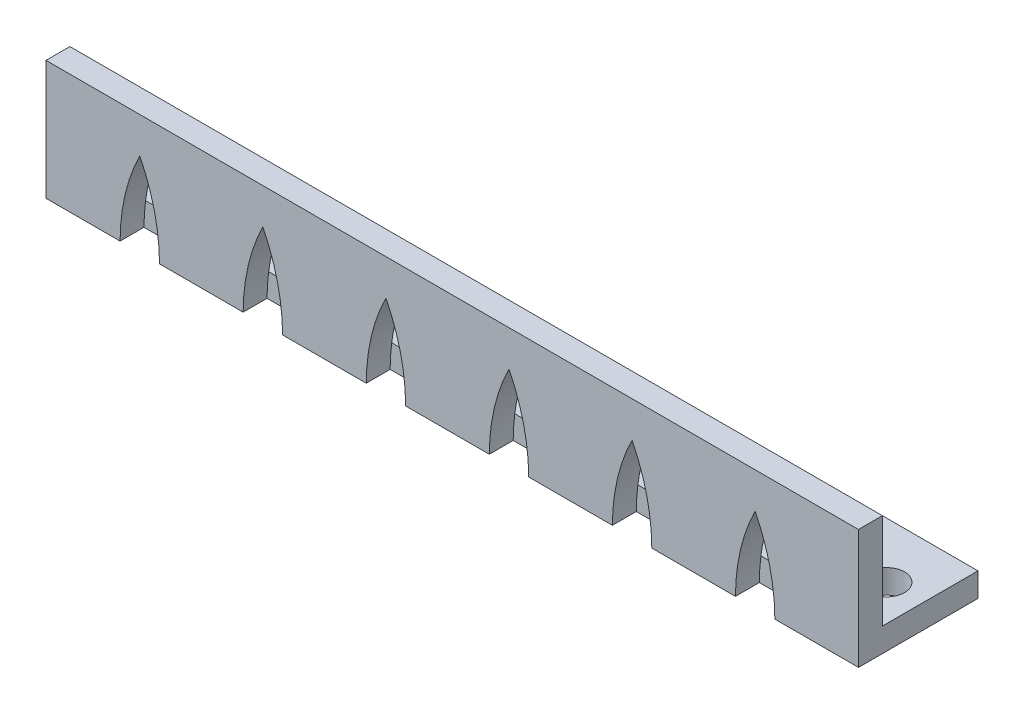
from build123d import *

# Parameters (mm, degrees)
SKETCH1_W                      = 68
SKETCH1_H                      = 10
SKETCH1_R                      = 1.5025
BOSS_EXTRUDE1_DEPTH            = 10
CUT_EXTRUDE1_REACH             = 7
SKETCH2_W                      = 68
SKETCH2_H                      = 8
CUT_EXTRUDE1_DIRECTION_2_DEPTH = 3
CUT_EXTRUDE2_DEPTH             = 2


with BuildPart() as part:
    # Sketch1 → Boss-Extrude1 (new body)
    with BuildSketch(Plane(origin=(0, 0, 0), x_dir=(1, 0, 0), z_dir=(0, 1, 0))):
        Rectangle(SKETCH1_W, SKETCH1_H)
        with Locations((-29, 0.35)):
            Circle(SKETCH1_R, mode=Mode.SUBTRACT)
        with Locations((-19, 0.35)):
            Circle(SKETCH1_R, mode=Mode.SUBTRACT)
        with Locations((-9, 0.35)):
            Circle(SKETCH1_R, mode=Mode.SUBTRACT)
        with Locations((1, 0.35)):
            Circle(SKETCH1_R, mode=Mode.SUBTRACT)
        with Locations((11, 0.35)):
            Circle(SKETCH1_R, mode=Mode.SUBTRACT)
        with Locations((21, 0.35)):
            Circle(SKETCH1_R, mode=Mode.SUBTRACT)
        with Locations((31, 0.35)):
            Circle(SKETCH1_R, mode=Mode.SUBTRACT)
    extrude(amount=BOSS_EXTRUDE1_DEPTH)

    # Sketch2 → Cut-Extrude1 (cut, up to next)
    with BuildSketch(Plane.XY, mode=Mode.PRIVATE) as cut_extrude1_sk1:
        with Locations((0, 6)):
            Rectangle(SKETCH2_W, SKETCH2_H)
    cut_extrude1_tool1 = extrude(cut_extrude1_sk1.sketch, amount=-CUT_EXTRUDE1_REACH, mode=Mode.PRIVATE) & part.part
    add(cut_extrude1_tool1.solids().sort_by_distance((0, 6, 0))[0], mode=Mode.SUBTRACT)

    # Sketch2 → Cut-Extrude1 direction 2 (cut)
    with BuildSketch(Plane.XY):
        with Locations((0, 6)):
            Rectangle(SKETCH2_W, SKETCH2_H)
    extrude(amount=CUT_EXTRUDE1_DIRECTION_2_DEPTH, mode=Mode.SUBTRACT)

    # Sketch3 → Cut-Extrude2 (cut)
    with BuildSketch(Plane.XY.offset(5)):
        with BuildLine():
            Line((23.7, 0), (27, 0))
            add(Edge.make_bspline(
                [(25.35, 7), (26.975838532, 3.728518175), (27, 0)],
                knots=[0, 0, 0, 1, 1, 1], degree=2))
            add(Edge.make_bspline(
                [(25.35, 7), (23.724161468, 3.728518175), (23.7, 0)],
                knots=[0, 0, 0, 1, 1, 1], degree=2))
        make_face()
        with BuildLine():
            Line((13.4, 0), (16.7, 0))
            add(Edge.make_bspline(
                [(15.05, 7), (16.675838532, 3.728518175), (16.7, 0)],
                knots=[0, 0, 0, 1, 1, 1], degree=2))
            add(Edge.make_bspline(
                [(15.05, 7), (13.424161468, 3.728518175), (13.4, 0)],
                knots=[0, 0, 0, 1, 1, 1], degree=2))
        make_face()
        with BuildLine():
            Line((3.1, 0), (6.4, 0))
            add(Edge.make_bspline(
                [(4.75, 7), (6.375838532, 3.728518175), (6.4, 0)],
                knots=[0, 0, 0, 1, 1, 1], degree=2))
            add(Edge.make_bspline(
                [(4.75, 7), (3.124161468, 3.728518175), (3.1, 0)],
                knots=[0, 0, 0, 1, 1, 1], degree=2))
        make_face()
        with BuildLine():
            Line((-7.2, 0), (-3.9, 0))
            add(Edge.make_bspline(
                [(-5.55, 7), (-3.924161468, 3.728518175), (-3.9, 0)],
                knots=[0, 0, 0, 1, 1, 1], degree=2))
            add(Edge.make_bspline(
                [(-5.55, 7), (-7.175838532, 3.728518175), (-7.2, 0)],
                knots=[0, 0, 0, 1, 1, 1], degree=2))
        make_face()
        with BuildLine():
            Line((-17.5, 0), (-14.2, 0))
            add(Edge.make_bspline(
                [(-15.85, 7), (-14.224161468, 3.728518175), (-14.2, 0)],
                knots=[0, 0, 0, 1, 1, 1], degree=2))
            add(Edge.make_bspline(
                [(-15.85, 7), (-17.475838532, 3.728518175), (-17.5, 0)],
                knots=[0, 0, 0, 1, 1, 1], degree=2))
        make_face()
        with BuildLine():
            Line((-27.8, 0), (-24.5, 0))
            add(Edge.make_bspline(
                [(-26.15, 7), (-24.524161468, 3.728518175), (-24.5, 0)],
                knots=[0, 0, 0, 1, 1, 1], degree=2))
            add(Edge.make_bspline(
                [(-26.15, 7), (-27.775838532, 3.728518175), (-27.8, 0)],
                knots=[0, 0, 0, 1, 1, 1], degree=2))
        make_face()
    extrude(amount=-CUT_EXTRUDE2_DEPTH, mode=Mode.SUBTRACT)


solid = part.part
